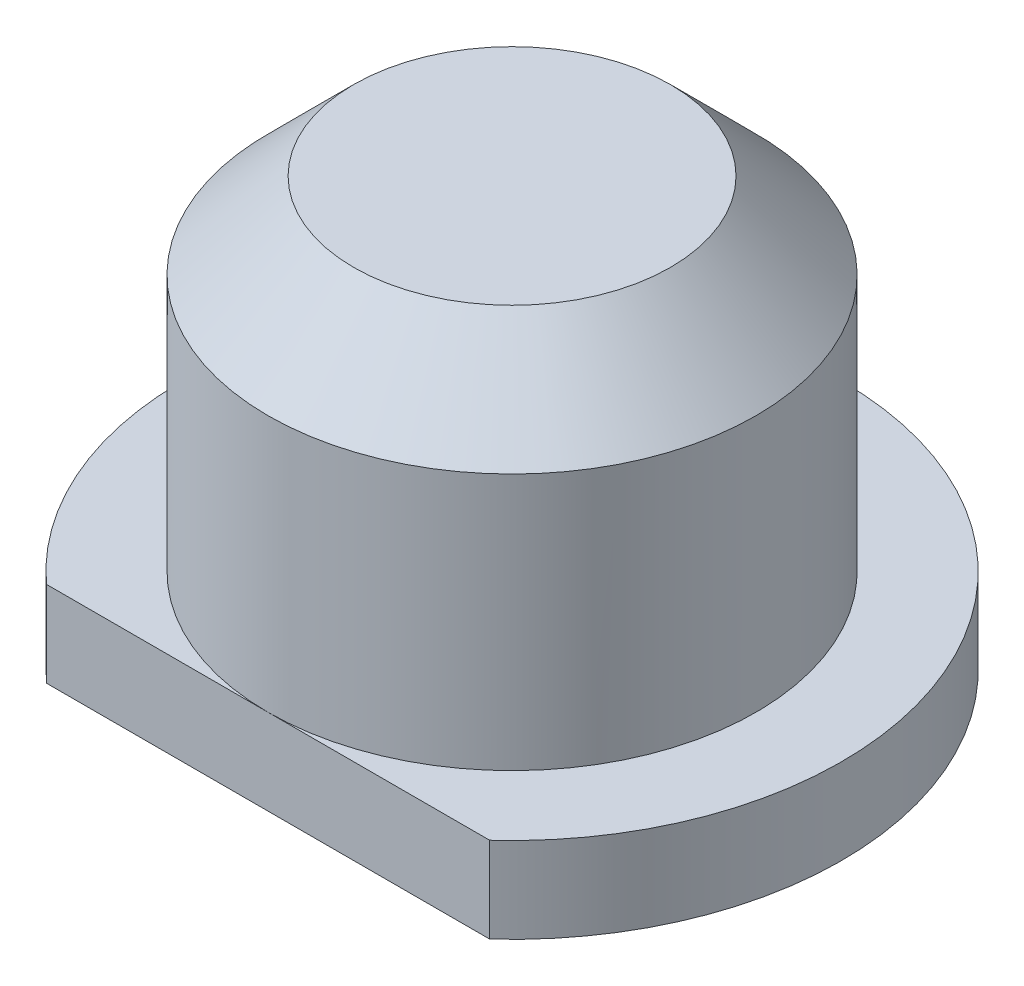
from build123d import *

# Parameters (mm, degrees)
CHAMFER1_SIZE      = 1
SKETCH2_W          = 8.626605672
SKETCH2_H          = 1.786618514
CUT_EXTRUDE1_DEPTH = 2


with BuildPart() as part:
    # Sketch1 → Revolve1 (revolve)
    with BuildSketch(Plane.XY):
        Polygon((0, 3.5), (2, 3.5), (2, 0), (3.85, 0), (3.85, 1), (2.85, 1), (2.85, 5), (0, 5), align=None)
    revolve(axis=Axis((0, 3.5, 0), (0, -1, 0)))

    # Chamfer1
    chamfer1_edges = [part.edges().sort_by_distance(p)[0] for p in [
        (-2.85, 5, 0),
    ]]
    chamfer(chamfer1_edges, length=CHAMFER1_SIZE)

    # Sketch2 → Cut-Extrude1 (cut, through all)
    with BuildSketch(Plane(origin=(0, 1, 0), x_dir=(1, 0, 0), z_dir=(0, 1, 0))):
        with Locations((1.724867015, -3.743309257)):
            Rectangle(SKETCH2_W, SKETCH2_H)
    extrude(amount=-CUT_EXTRUDE1_DEPTH, mode=Mode.SUBTRACT)


solid = part.part
